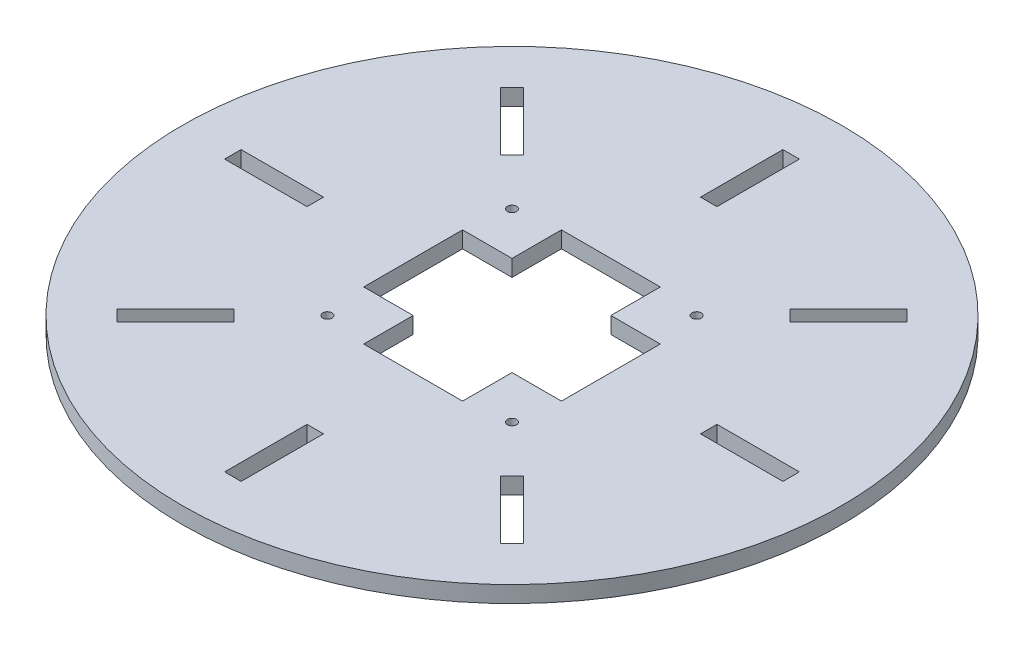
from build123d import *

# Parameters (mm, degrees)
SKETCH_1_R               = 100
EXTRUDE_1_DEPTH          = 5
SKETCH_2_R               = 1.4
CUT_EXTRUDE_1_DEPTH      = 5
SKETCH_4_W               = 5
SKETCH_4_H               = 25
CUT_EXTRUDE_2_DEPTH      = 5
PATTERN_CIRCULAR_2_COUNT = 4
PATTERN_CIRCULAR_2_ANGLE = 135
SKETCH_5_W               = 30
SKETCH_5_H               = 30
SKETCH_5_H_2             = 15
SKETCH_5_W_2             = 15
CUT_EXTRUDE_3_DEPTH      = 5


with BuildPart() as part:
    # 草图1 → 凸台-拉伸1 (new body)
    with BuildSketch(Plane(origin=(0, 0, 0), x_dir=(1, 0, 0), z_dir=(0, 1, 0))):
        Circle(SKETCH_1_R)
    extrude(amount=EXTRUDE_1_DEPTH)

    # 草图2 → 切除-拉伸1 (cut)
    with BuildSketch(Plane(origin=(0, 5, 0), x_dir=(1, 0, 0), z_dir=(0, 1, 0))):
        with Locations((28, 28)):
            Circle(SKETCH_2_R)
        with Locations((28, -28)):
            Circle(SKETCH_2_R)
        with Locations((-28, -28)):
            Circle(SKETCH_2_R)
        with Locations((-28, 28)):
            Circle(SKETCH_2_R)
    extrude(amount=-CUT_EXTRUDE_1_DEPTH, mode=Mode.SUBTRACT)

    # 草图4 → 切除-拉伸2 (cut)
    with BuildSketch(Plane(origin=(0, 5, 0), x_dir=(1, 0, 0), z_dir=(0, 1, 0))):
        with Locations((0, 72.2)):
            Rectangle(SKETCH_4_W, SKETCH_4_H)
        with Locations((0, -72.2)):
            Rectangle(SKETCH_4_W, SKETCH_4_H)
    cut_extrude_2 = extrude(amount=-CUT_EXTRUDE_2_DEPTH, mode=Mode.SUBTRACT)

    # 阵列(圆周)2: 切除-拉伸2 ×4 about axis
    pattern_circular_2_axis = Axis((0, 0, 0), (0, 1, 0))
    for i in range(1, PATTERN_CIRCULAR_2_COUNT):
        add(cut_extrude_2.rotate(pattern_circular_2_axis, i * PATTERN_CIRCULAR_2_ANGLE / (PATTERN_CIRCULAR_2_COUNT - 1)), mode=Mode.SUBTRACT)

    # 草图5 → 切除-拉伸3 (cut)
    with BuildSketch(Plane(origin=(0, 5, 0), x_dir=(1, 0, 0), z_dir=(0, 1, 0))):
        Rectangle(SKETCH_5_W, SKETCH_5_H)
        with Locations((0, 22.5)):
            Rectangle(SKETCH_5_W, SKETCH_5_H_2)
        with Locations((22.5, 0)):
            Rectangle(SKETCH_5_W_2, SKETCH_5_H)
        with Locations((0, -22.5)):
            Rectangle(SKETCH_5_W, SKETCH_5_H_2)
        with Locations((-22.5, 0)):
            Rectangle(SKETCH_5_W_2, SKETCH_5_H)
    extrude(amount=-CUT_EXTRUDE_3_DEPTH, mode=Mode.SUBTRACT)


solid = part.part
